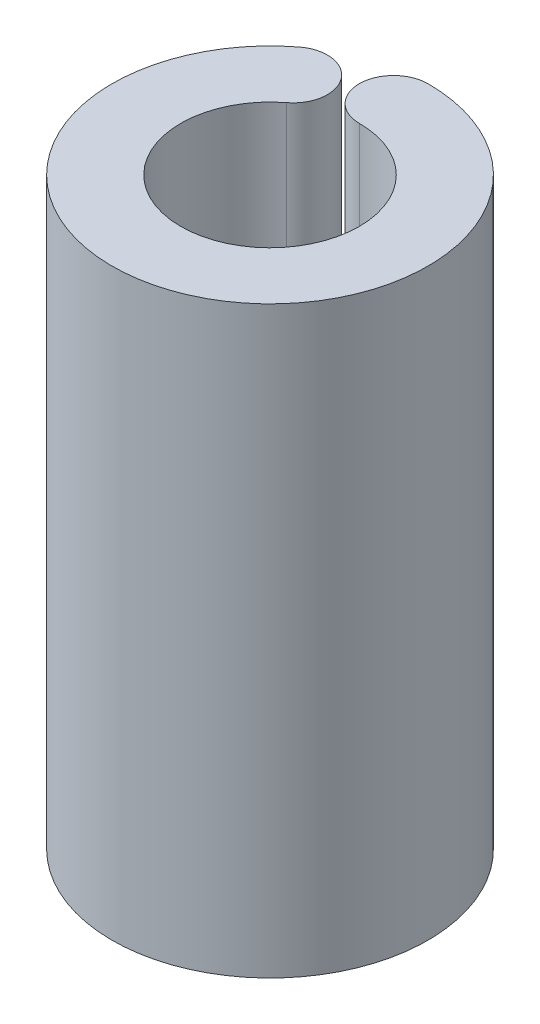
from build123d import *

# Parameters (mm, degrees)
BOSS_EXTRUDE1_DEPTH = 17


with BuildPart() as part:
    # Sketch1 → Boss-Extrude1 (new body)
    with BuildSketch(Plane(origin=(0, 0, 0), x_dir=(1, 0, 0), z_dir=(0, 1, 0))):
        with BuildLine():
            ThreePointArc((0, 2.6), (0.833935879, -2.4626309), (-1.579750972, 2.065039192))
            ThreePointArc((-1.579750972, 2.065039192), (-1.393101657, 3.466881563), (-2.794944028, 3.653530879))
            ThreePointArc((-2.794944028, 3.653530879), (1.475425016, -4.356962362), (0, 4.6))
            ThreePointArc((0, 4.6), (-1, 3.6), (0, 2.6))
        make_face()
    extrude(amount=BOSS_EXTRUDE1_DEPTH)


solid = part.part
